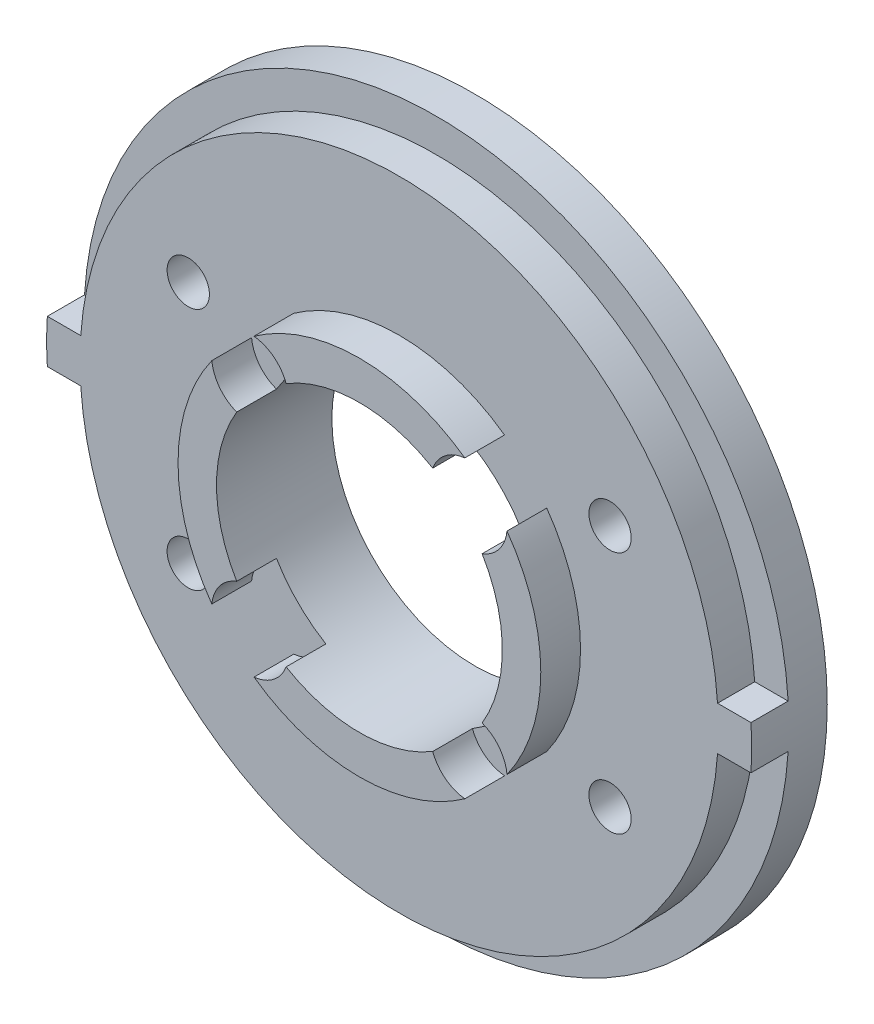
from build123d import *

# Parameters (mm, degrees)
SKETCH1_R           = 27.5
SKETCH1_R_2         = 11.15
BOSS_EXTRUDE1_DEPTH = 9
CUT_EXTRUDE1_START  = 9
CUT_EXTRUDE1_DEPTH  = 6
CUT_EXTRUDE2_START  = 9
SKETCH3_R           = 39.185897799
SKETCH3_R_2         = 14.15
CUT_EXTRUDE2_DEPTH  = 3.1
CUT_EXTRUDE3_START  = 5.9
SKETCH4_R           = 1.65
CUT_EXTRUDE3_DEPTH  = 6.9
CUT_EXTRUDE9_START  = 9
SKETCH9_R           = 3
CUT_EXTRUDE9_DEPTH  = 3.1
SKETCH8_R           = 3.3
CUT_EXTRUDE10_DEPTH = 2.1


with BuildPart() as part:
    # Sketch1 → Boss-Extrude1 (new body)
    with BuildSketch(Plane.XY):
        Circle(SKETCH1_R)
        Circle(SKETCH1_R_2, mode=Mode.SUBTRACT)
    extrude(amount=BOSS_EXTRUDE1_DEPTH)

    # Sketch2 → Cut-Extrude1 (cut)
    with BuildSketch(Plane.XY.offset(CUT_EXTRUDE1_START)):
        with BuildLine():
            Line((-27.447404249, 1.7), (-24.84017663, 1.7))
            ThreePointArc((-24.84017663, 1.7), (0, 24.898280563), (24.84017663, 1.7))
            Line((24.84017663, 1.7), (27.447404249, 1.7))
            ThreePointArc((27.447404249, 1.7), (0, 27.5), (-27.447404249, 1.7))
        make_face()
        with BuildLine():
            Line((27.447404249, -1.7), (24.841900088, -1.7))
            ThreePointArc((24.841900088, -1.7), (0, -24.9), (-24.841900088, -1.7))
            Line((-24.841900088, -1.7), (-27.447404249, -1.7))
            ThreePointArc((-27.447404249, -1.7), (0, -27.5), (27.447404249, -1.7))
        make_face()
    extrude(amount=-CUT_EXTRUDE1_DEPTH, mode=Mode.SUBTRACT)

    # Sketch3 → Cut-Extrude2 (cut)
    with BuildSketch(Plane.XY.offset(CUT_EXTRUDE2_START)):
        Circle(SKETCH3_R)
        Circle(SKETCH3_R_2, mode=Mode.SUBTRACT)
    extrude(amount=-CUT_EXTRUDE2_DEPTH, mode=Mode.SUBTRACT)

    # Sketch4 → Cut-Extrude3 (cut, through all)
    with BuildSketch(Plane.XY.offset(CUT_EXTRUDE3_START)):
        with Locations((-16.454482672, 9.5)):
            Circle(SKETCH4_R)
        with Locations((16.454482672, 9.5)):
            Circle(SKETCH4_R)
        with Locations((16.454482672, -9.5)):
            Circle(SKETCH4_R)
        with Locations((-16.454482672, -9.5)):
            Circle(SKETCH4_R)
    extrude(amount=-CUT_EXTRUDE3_DEPTH, mode=Mode.SUBTRACT)

    # Sketch9 → Cut-Extrude9 (cut)
    with BuildSketch(Plane.XY.offset(CUT_EXTRUDE9_START)):
        with Locations((-8.530989978, 8.530989978)):
            Circle(SKETCH9_R)
        with Locations((8.530989978, 8.530989978)):
            Circle(SKETCH9_R)
        with Locations((8.530989978, -8.530989978)):
            Circle(SKETCH9_R)
        with Locations((-8.530989978, -8.530989978)):
            Circle(SKETCH9_R)
    extrude(amount=-CUT_EXTRUDE9_DEPTH, mode=Mode.SUBTRACT)

    # Sketch8 → Cut-Extrude10 (cut)
    with BuildSketch(Plane.XY):
        with Locations((-16.454482672, 9.5)):
            Circle(SKETCH8_R)
        with Locations((-16.454482672, -9.5)):
            Circle(SKETCH8_R)
        with Locations((16.454482672, -9.5)):
            Circle(SKETCH8_R)
        with Locations((16.454482672, 9.5)):
            Circle(SKETCH8_R)
    extrude(amount=CUT_EXTRUDE10_DEPTH, mode=Mode.SUBTRACT)


solid = part.part
